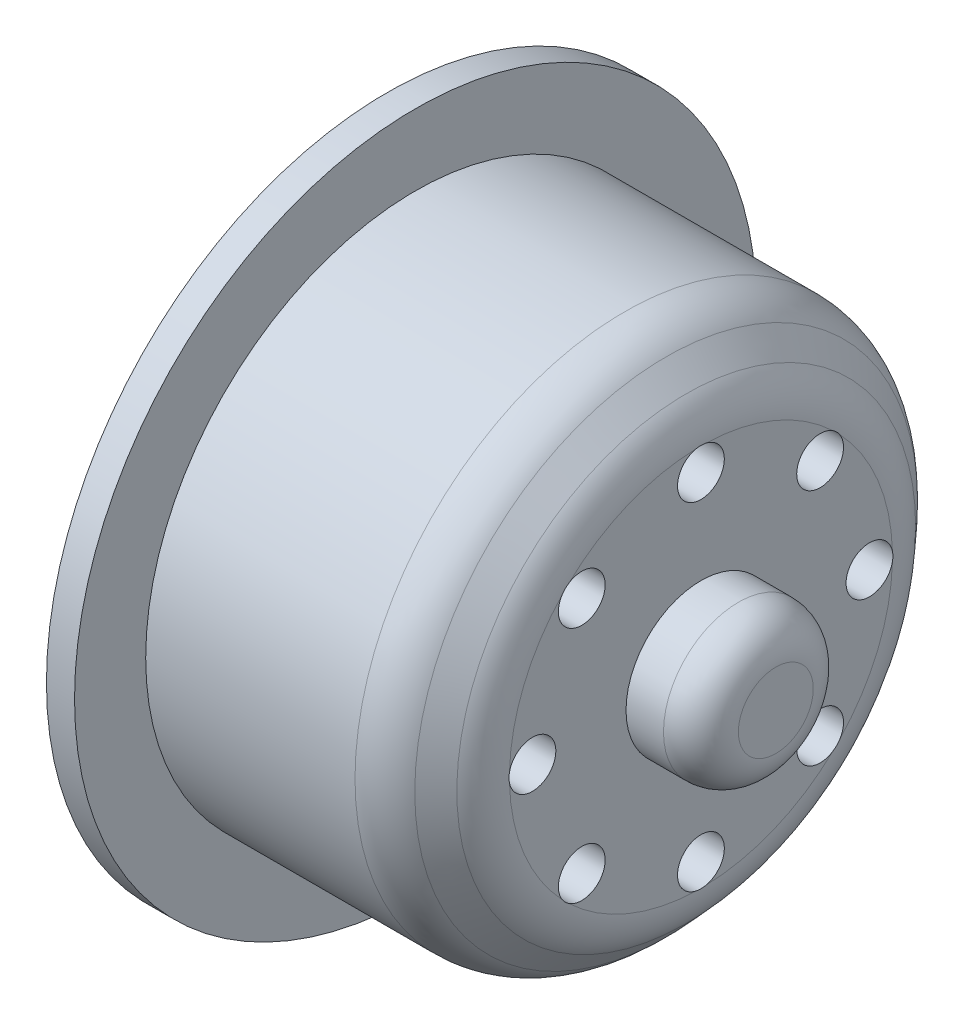
from build123d import *

# Parameters (mm, degrees)
FILLET1_R          = 2
SKETCH4_R          = 5.6
CUT_EXTRUDE3_DEPTH = 6
SKETCH5_R          = 1.25
CUT_EXTRUDE4_DEPTH = 16.75
SKETCH6_R          = 2.5
CUT_EXTRUDE5_DEPTH = 11.75
FILLET2_R          = 3


with BuildPart() as part:
    # Sketch1 → Revolve1 (revolve)
    with BuildSketch(Plane(origin=(0, 0, 0), x_dir=(1, 0, 0), z_dir=(0, 1, 0))):
        Polygon((-4.630434783, 14.4), (7.869565217, 14.4), (10.619565217, 11.390476118), (10.619565217, 4), (14.619565217, 4), (14.619565217, 0), (13.372742768, 0), (-6.130434783, 0), (-6.130434783, 18.2), (-4.630434783, 18.2), align=None)
    revolve(axis=Axis((-12.391304348, 0, 0), (1, 0, 0)))

    # Fillet1
    fillet1_edges = [part.edges().sort_by_distance(p)[0] for p in [
        (14.619565217, 0, 4),
    ]]
    fillet(fillet1_edges, radius=FILLET1_R)

    # Sketch4 → Cut-Extrude3 (cut)
    with BuildSketch(Plane.ZY.offset(6.130434783)):
        Circle(SKETCH4_R)
    extrude(amount=-CUT_EXTRUDE3_DEPTH, mode=Mode.SUBTRACT)

    # Sketch5 → Cut-Extrude4 (cut)
    with BuildSketch(Plane(origin=(10.619565217, 0, 0), x_dir=(0, 0, -1), z_dir=(1, 0, 0))):
        with Locations((0, 9)):
            Circle(SKETCH5_R)
        with Locations((6.363961031, 6.363961031)):
            Circle(SKETCH5_R)
        with Locations((9, 0)):
            Circle(SKETCH5_R)
        with Locations((6.363961031, -6.363961031)):
            Circle(SKETCH5_R)
        with Locations((0, -9)):
            Circle(SKETCH5_R)
        with Locations((-6.363961031, -6.363961031)):
            Circle(SKETCH5_R)
        with Locations((-9, 0)):
            Circle(SKETCH5_R)
        with Locations((-6.363961031, 6.363961031)):
            Circle(SKETCH5_R)
    extrude(amount=-CUT_EXTRUDE4_DEPTH, mode=Mode.SUBTRACT)

    # Sketch6 → Cut-Extrude5 (cut)
    with BuildSketch(Plane.ZY.offset(6.130434783)):
        with Locations((0, 9)):
            Circle(SKETCH6_R)
        with Locations((6.363961031, 6.363961031)):
            Circle(SKETCH6_R)
        with Locations((9, 0)):
            Circle(SKETCH6_R)
        with Locations((6.363961031, -6.363961031)):
            Circle(SKETCH6_R)
        with Locations((0, -9)):
            Circle(SKETCH6_R)
        with Locations((-6.363961031, -6.363961031)):
            Circle(SKETCH6_R)
        with Locations((-9, 0)):
            Circle(SKETCH6_R)
        with Locations((-6.363961031, 6.363961031)):
            Circle(SKETCH6_R)
    extrude(amount=-CUT_EXTRUDE5_DEPTH, mode=Mode.SUBTRACT)

    # Fillet2
    fillet2_edges = [part.edges().sort_by_distance(p)[0] for p in [
        (7.869565217, 0, 14.4),
        (10.619565217, 0, 11.390476118),
    ]]
    fillet(fillet2_edges, radius=FILLET2_R)


solid = part.part
